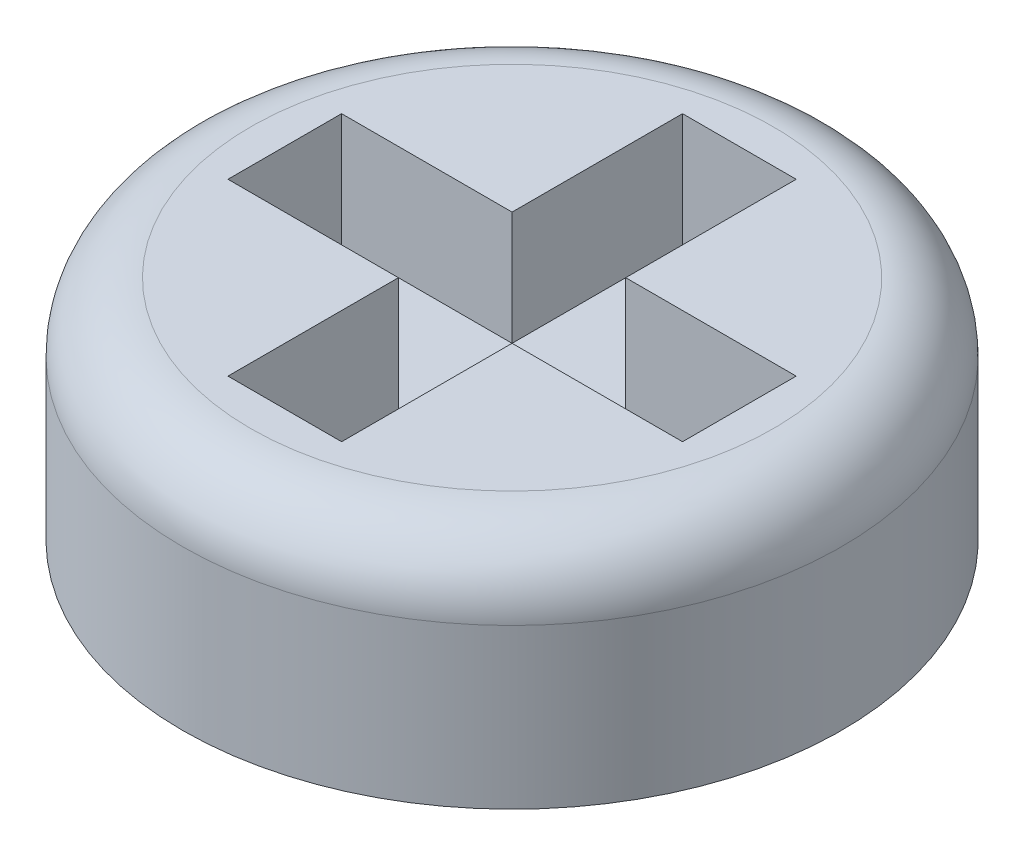
from build123d import *

# Parameters (mm, degrees)
SKETCH1_R           = 1.45
BOSS_EXTRUDE1_DEPTH = 1
CUT_EXTRUDE1_DEPTH  = 0.5
FILLET3_R           = 0.3


with BuildPart() as part:
    # Sketch1 → Boss-Extrude1 (new body)
    with BuildSketch(Plane(origin=(0, 0, 0), x_dir=(1, 0, 0), z_dir=(0, 1, 0))):
        Circle(SKETCH1_R)
    extrude(amount=BOSS_EXTRUDE1_DEPTH)

    # Sketch2 → Cut-Extrude1 (cut)
    with BuildSketch(Plane(origin=(0, 1, 0), x_dir=(1, 0, 0), z_dir=(0, 1, 0))):
        Polygon((-0.25, 0.25), (-0.25, 1), (0.25, 1), (0.25, 0.25), (1, 0.25), (1, -0.25), (0.25, -0.25), (0.25, -1), (-0.25, -1), (-0.25, -0.25), (-1, -0.25), (-1, 0.25), align=None)
    extrude(amount=-CUT_EXTRUDE1_DEPTH, mode=Mode.SUBTRACT)

    # Fillet3
    fillet3_edges = [part.edges().sort_by_distance(p)[0] for p in [
        (-1.45, 1, 0),
    ]]
    fillet(fillet3_edges, radius=FILLET3_R)


solid = part.part
